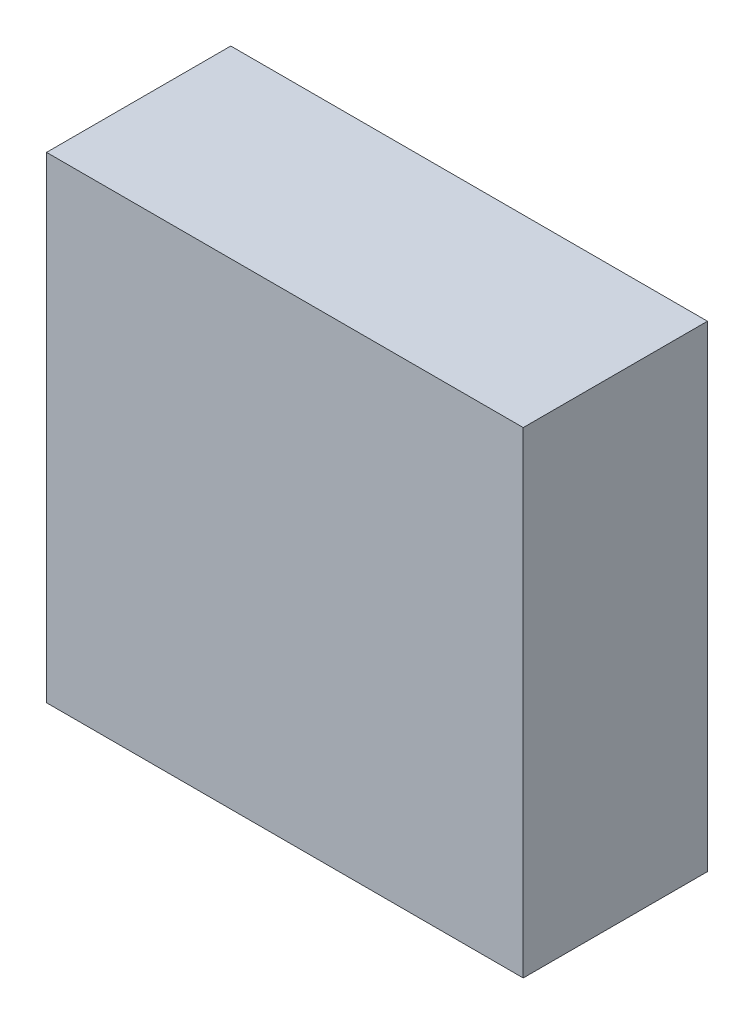
from build123d import *

# Parameters (mm, degrees)
SKETCH1_W           = 59
SKETCH1_H           = 59
BOSS_EXTRUDE1_DEPTH = 22.8


with BuildPart() as part:
    # Sketch1 → Boss-Extrude1 (new body)
    with BuildSketch(Plane.XY):
        with Locations((29.5, 29.5)):
            Rectangle(SKETCH1_W, SKETCH1_H)
    extrude(amount=BOSS_EXTRUDE1_DEPTH)


solid = part.part
